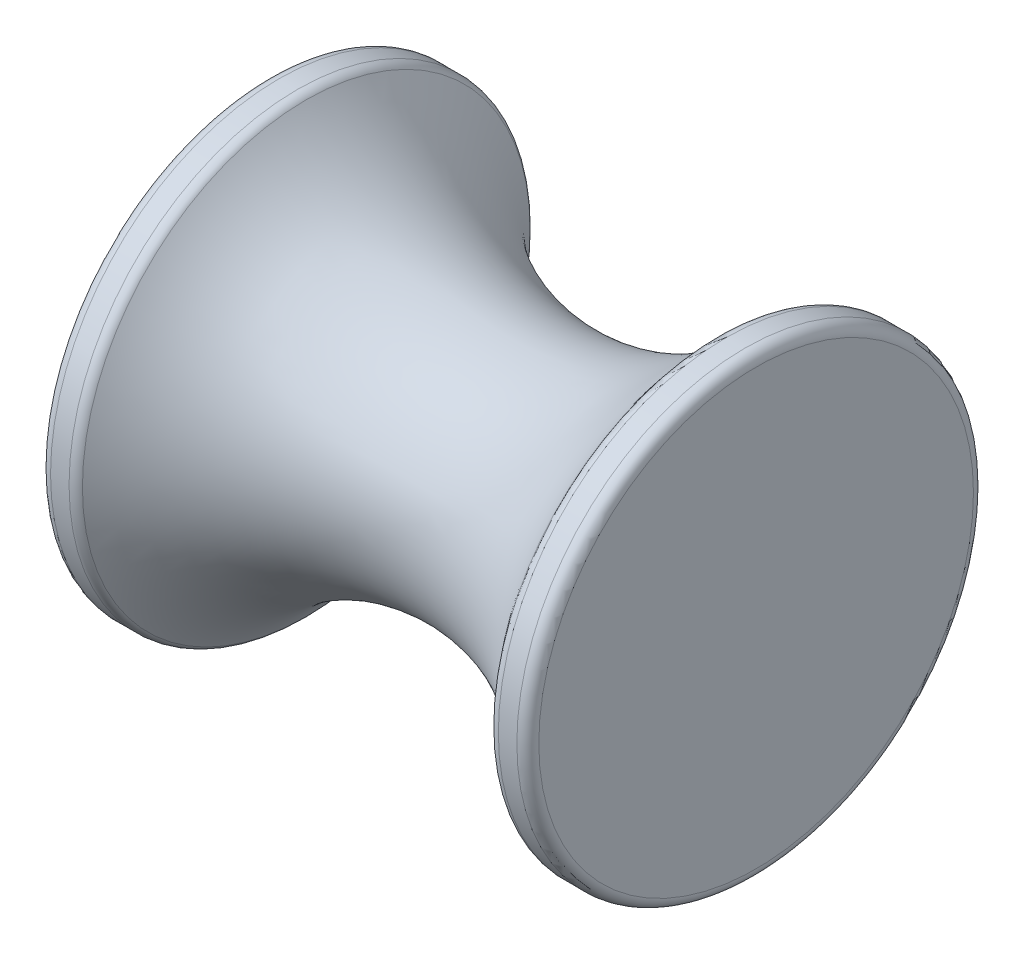
from build123d import *

# Parameters (mm, degrees)
FILLET2_R = 0.79375


with BuildPart() as part:
    # Sketch1 → Revolve1 (revolve)
    with BuildSketch(Plane.XY):
        with BuildLine():
            Line((-17.653, 0), (17.653, 0))
            Line((17.653, 0), (17.653, 16.51))
            Line((17.653, 16.51), (15.113, 16.51))
            ThreePointArc((15.113, 16.51), (0, 8.636), (-15.113, 16.51))
            Line((-15.113, 16.51), (-17.653, 16.51))
            Line((-17.653, 16.51), (-17.653, 0))
        make_face()
    revolve(axis=Axis((-17.653, 0, 0), (1, 0, 0)))

    # Fillet2
    fillet2_edges = [part.edges().sort_by_distance(p)[0] for p in [
        (-17.653, -16.51, 0),
        (-15.113, -16.51, 0),
        (15.113, -16.51, 0),
        (17.653, -16.51, 0),
    ]]
    fillet(fillet2_edges, radius=FILLET2_R)


solid = part.part
